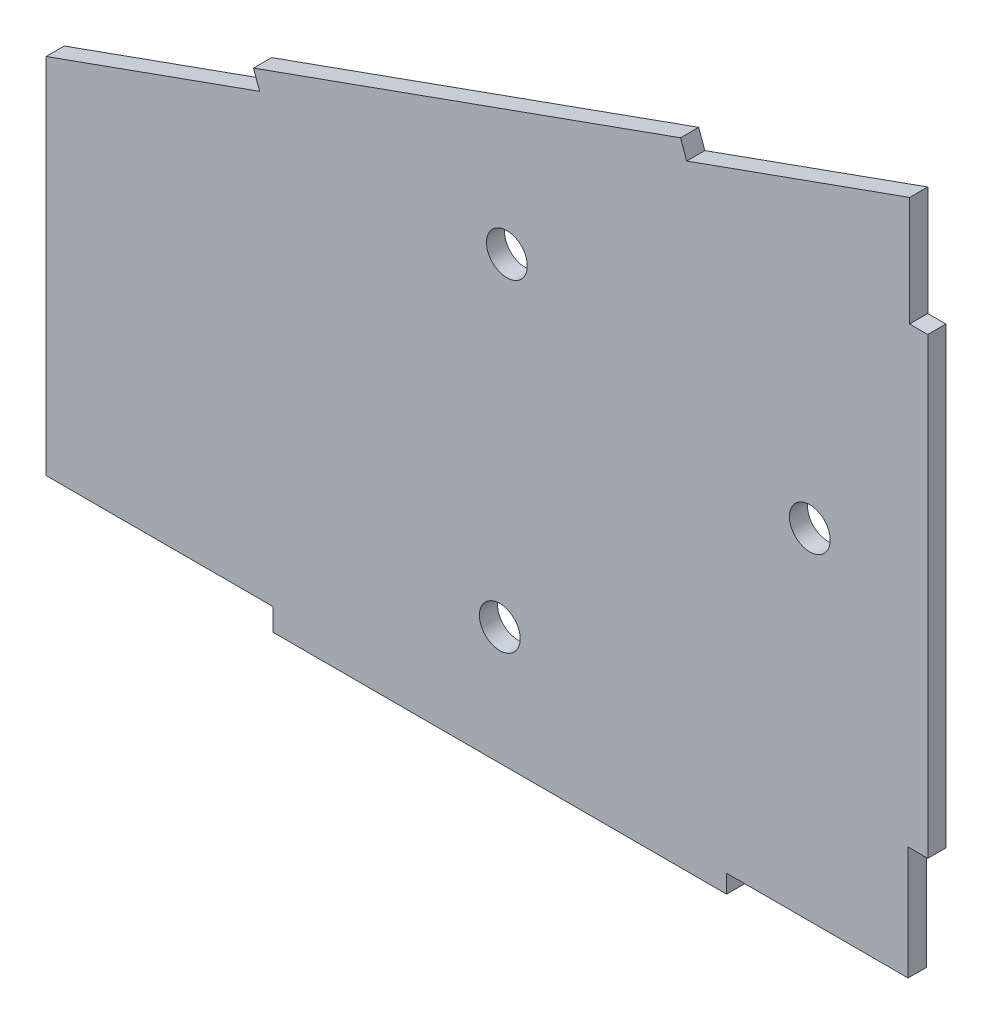
from build123d import *

# Parameters (mm, degrees)
EXTRUDE_1_DEPTH          = 2
SKETCH_3_R               = 2.25
CUT_EXTRUDE_1_DEPTH      = 2
CUT_EXTRUDE_1_DEPTH_BACK = 10


with BuildPart() as part:
    # 草图2 → 凸台-拉伸1 (new body)
    with BuildSketch(Plane.XY):
        Polygon((30.22420133, 24.680203113), (30.22420133, 36.760203113), (5.656415061, 27.949194211), (4.981241965, 29.831783197), (-42.083482687, 12.952455799), (-41.408309591, 11.069866813), (-64.940671917, 2.630203113), (-64.940671917, -37.369796887), (-39.940671917, -37.369796887), (-39.940671917, -39.819796887), (10.059328083, -39.819796887), (10.059328083, -37.819796887), (30.059328083, -37.819796887), (30.059328083, -25.319796887), (32.22420133, -25.319796887), (32.22420133, 24.680203113), align=None)
    extrude(amount=EXTRUDE_1_DEPTH)

    # 草图3 → 切除-拉伸1 (cut, two sides)
    with BuildSketch(Plane.XY) as cut_extrude_1_sk:
        with Locations((-14.162495237, 9.155291089)):
            Circle(SKETCH_3_R)
        with Locations((19.22420133, -0.319796887)):
            Circle(SKETCH_3_R)
        with Locations((-14.940671917, -26.819796887)):
            Circle(SKETCH_3_R)
    extrude(amount=CUT_EXTRUDE_1_DEPTH, mode=Mode.SUBTRACT)
    extrude(cut_extrude_1_sk.sketch, amount=-CUT_EXTRUDE_1_DEPTH_BACK, mode=Mode.SUBTRACT)


solid = part.part
